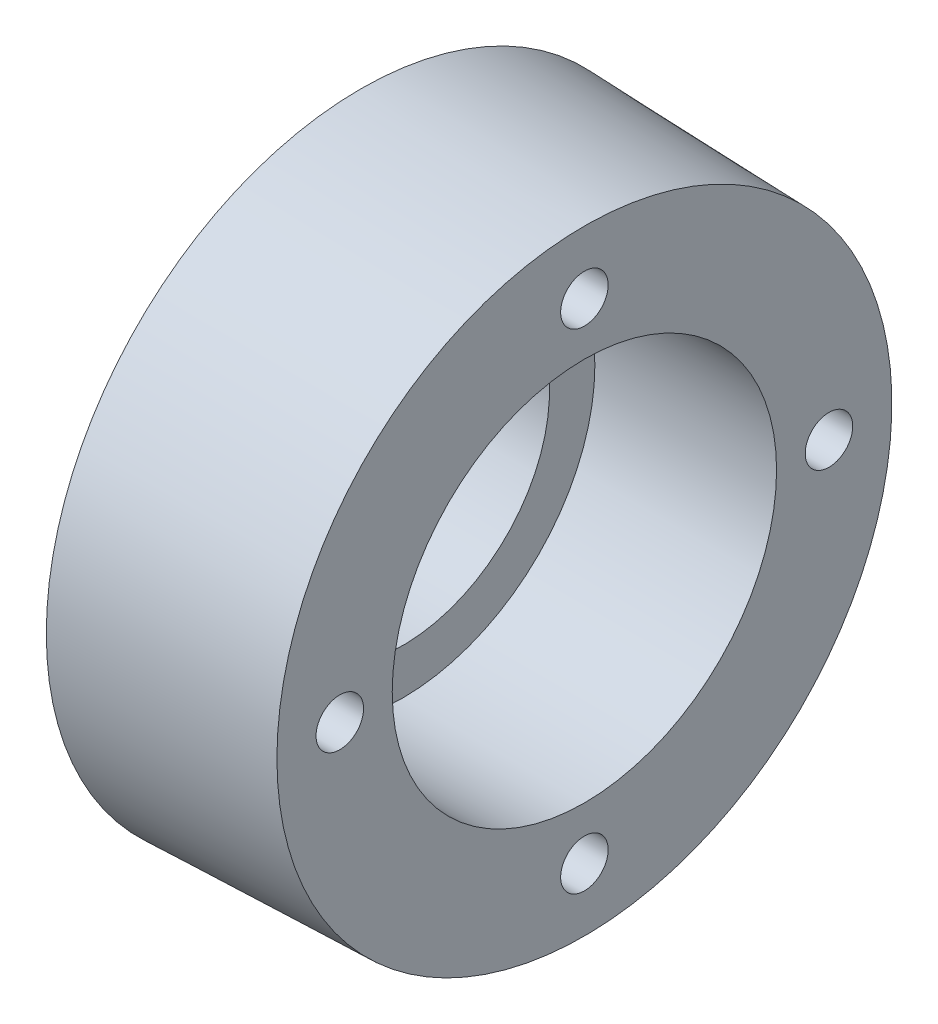
from build123d import *

# Parameters (mm, degrees)
DAIRESEL_KAPLAMA2_COUNT = 4


with BuildPart() as part:
    # Çizim1 → Döndür1 (revolve)
    with BuildSketch(Plane.XY):
        Polygon((0, 21), (11, 21), (11, 27.5), (37, 27.5), (37, 44), (5, 45), (5, 28), (0, 28), align=None)
    revolve(axis=Axis((0, 0, 0), (1, 0, 0)))

    # Çizim4 → M8 Dişli Delik1 (revolve, cut)
    with BuildSketch(Plane(origin=(37, 35, 0), x_dir=(0, 0, -1), z_dir=(0, 1, 0))):
        Polygon((0, 0), (0, 24.292926105), (3.4, 22.25), (3.4, 0), align=None)
    m8_di_li_delik1 = revolve(axis=Axis((43.35, 35, 0), (-1, 0, 0)), mode=Mode.SUBTRACT)

    # Dairesel Kaplama2: M8 Dişli Delik1 ×4 about axis
    dairesel_kaplama2_axis = Axis((0, 0, 0), (1, 0, 0))
    for i in range(1, DAIRESEL_KAPLAMA2_COUNT):
        add(m8_di_li_delik1.rotate(dairesel_kaplama2_axis, i * 360 / DAIRESEL_KAPLAMA2_COUNT), mode=Mode.SUBTRACT)


solid = part.part
